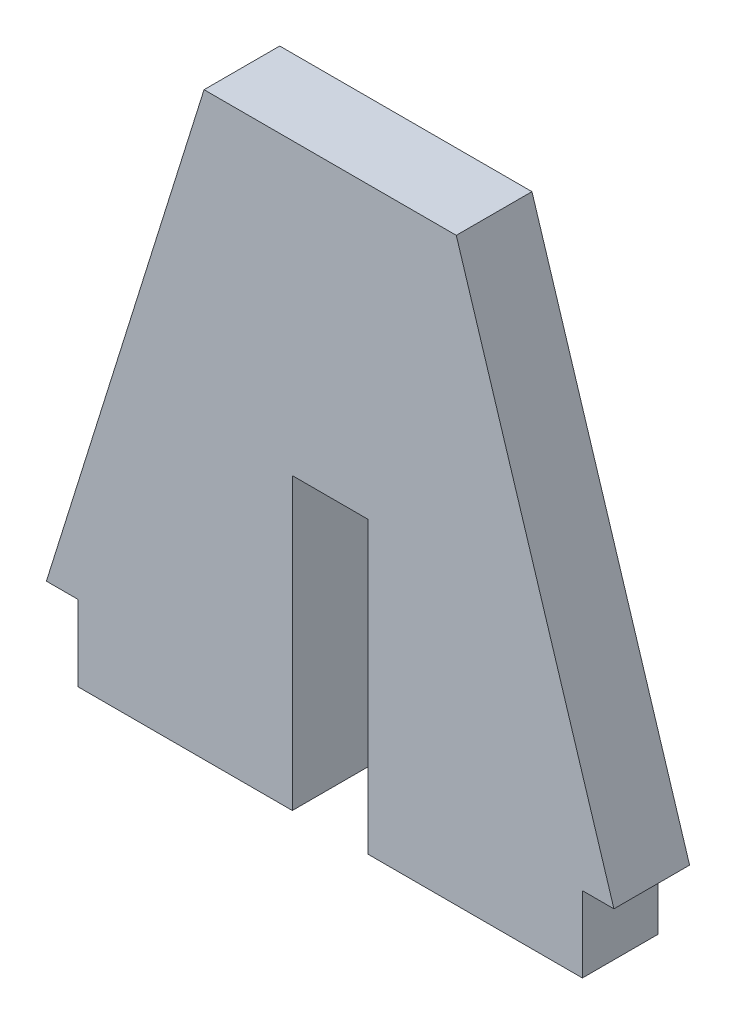
from build123d import *

# Parameters (mm, degrees)
BOSS_EXTRUDE1_DEPTH = 3
SKETCH2_W           = 6
SKETCH2_H           = 23
CUT_EXTRUDE1_DEPTH  = 7


with BuildPart() as part:
    # Sketch1 → Boss-Extrude1 (new body, symmetric)
    with BuildSketch(Plane.XY):
        Polygon((-20, 0), (20, 0), (20, 6), (22.5, 6), (10, 46), (-10, 46), (-22.5, 6), (-20, 6), align=None)
    extrude(amount=BOSS_EXTRUDE1_DEPTH, both=True)

    # Sketch2 → Cut-Extrude1 (cut, through all)
    with BuildSketch(Plane.XY.offset(3)):
        with Locations((0, 11.5)):
            Rectangle(SKETCH2_W, SKETCH2_H)
    extrude(amount=-CUT_EXTRUDE1_DEPTH, mode=Mode.SUBTRACT)


solid = part.part
